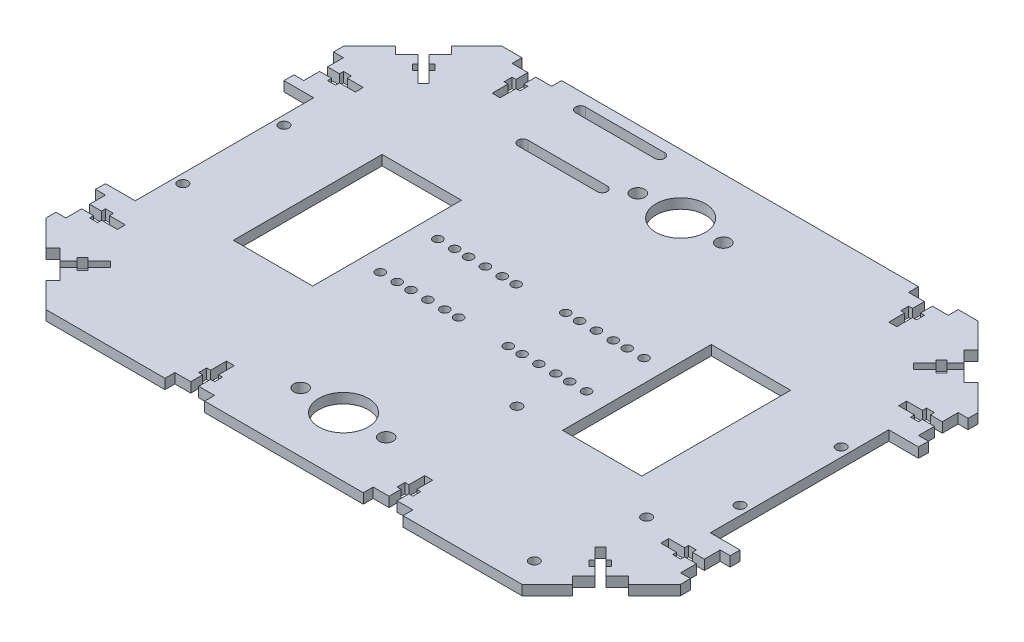
from build123d import *

# Parameters (mm, degrees)
SKETCH2_W                                  = 320
SKETCH2_H                                  = 230
BOSS_EXTRUDE1_DEPTH                        = 5
SKETCH5_W                                  = 15
SKETCH5_H                                  = 90
SKETCH5_W_2                                = 40
SKETCH5_H_2                                = 75
CUT_EXTRUDE1_DEPTH                         = 6
CHAMFER1_SIZE                              = 40
CHAMFER2_SIZE                              = 40
CHAMFER3_SIZE                              = 40
CHAMFER4_SIZE                              = 40
SKETCH22_R                                 = 2.5
CUT_EXTRUDE10_DEPTH                        = 10
SKETCH27_R                                 = 2.25
CUT_EXTRUDE11_DEPTH                        = 10
SKETCH29_R                                 = 3.5
CUT_EXTRUDE12_DEPTH                        = 10
MIRROR7_AT_THE_SECOND_PLANE_COPY_1_SKETC_R = 3.5
MIRROR7_AT_THE_SECOND_PLANE_COPY_1_DEPTH   = 10
CUT_EXTRUDE14_DEPTH                        = 10
SKETCH33_R                                 = 2.5
CUT_EXTRUDE15_DEPTH                        = 10
SKETCH35_W                                 = 20
SKETCH35_H                                 = 5
SKETCH35_W_2                               = 4
SKETCH35_H_2                               = 6
SKETCH35_W_3                               = 2
SKETCH35_H_3                               = 4
SKETCH35_H_4                               = 8
CUT_EXTRUDE16_DEPTH                        = 10
SKETCH36_W                                 = 20
SKETCH36_H                                 = 5
SKETCH36_W_2                               = 4
SKETCH36_H_2                               = 6
SKETCH36_H_3                               = 4
SKETCH36_W_3                               = 2
SKETCH36_H_4                               = 8
CUT_EXTRUDE17_DEPTH                        = 10
CUT_EXTRUDE18_DEPTH                        = 10
MIRROR10_AT_THE_SECOND_PLANE_COPY_1_DEPTH  = 10
CUT_EXTRUDE19_DEPTH                        = 10
MIRROR11_AT_THE_SECOND_PLANE_COPY_1_DEPTH  = 10
SKETCH40_R                                 = 12.5
CUT_EXTRUDE20_DEPTH                        = 10


with BuildPart() as part:
    # Sketch2 → Boss-Extrude1 (new body)
    with BuildSketch(Plane(origin=(0, 0, 0), x_dir=(1, 0, 0), z_dir=(0, 1, 0))):
        Rectangle(SKETCH2_W, SKETCH2_H)
    extrude(amount=BOSS_EXTRUDE1_DEPTH)

    # Sketch5 → Cut-Extrude1 (cut, through all)
    with BuildSketch(Plane(origin=(0, 5, 0), x_dir=(1, 0, 0), z_dir=(0, 1, 0))):
        with Locations((-152.5, 0)):
            Rectangle(SKETCH5_W, SKETCH5_H)
        with Locations((-83, 0)):
            Rectangle(SKETCH5_W_2, SKETCH5_H_2)
        with Locations((83, 0)):
            Rectangle(SKETCH5_W_2, SKETCH5_H_2)
        with Locations((152.5, 0)):
            Rectangle(SKETCH5_W, SKETCH5_H)
    extrude(amount=-CUT_EXTRUDE1_DEPTH, mode=Mode.SUBTRACT)

    # Chamfer1
    chamfer1_edges = [part.edges().sort_by_distance(p)[0] for p in [
        (-160, 2.5, -115),
    ]]
    chamfer(chamfer1_edges, length=CHAMFER1_SIZE)

    # Chamfer2
    chamfer2_edges = [part.edges().sort_by_distance(p)[0] for p in [
        (160, 2.5, -115),
    ]]
    chamfer(chamfer2_edges, length=CHAMFER2_SIZE)

    # Chamfer3
    chamfer3_edges = [part.edges().sort_by_distance(p)[0] for p in [
        (-160, 2.5, 115),
    ]]
    chamfer(chamfer3_edges, length=CHAMFER3_SIZE)

    # Chamfer4
    chamfer4_edges = [part.edges().sort_by_distance(p)[0] for p in [
        (160, 2.5, 115),
    ]]
    chamfer(chamfer4_edges, length=CHAMFER4_SIZE)

    # Sketch22 → Cut-Extrude10 (cut)
    with BuildSketch(Plane(origin=(0, 5, 0), x_dir=(1, 0, 0), z_dir=(0, 1, 0))):
        with Locations((-140.5, 25.5)):
            Circle(SKETCH22_R)
        with Locations((-140.5, -25.5)):
            Circle(SKETCH22_R)
    cut_extrude10 = extrude(amount=-CUT_EXTRUDE10_DEPTH, mode=Mode.SUBTRACT)

    # Mirror5: Cut-Extrude10 across plane
    add(cut_extrude10.mirror(Plane(origin=(0, 0, 0), x_dir=(0, 0, 1), z_dir=(1, 0, 0))), mode=Mode.SUBTRACT)

    # Sketch27 → Cut-Extrude11 (cut)
    with BuildSketch(Plane(origin=(0, 5, 0), x_dir=(1, 0, 0), z_dir=(0, 1, 0))):
        with Locations((-52, 14.579978174)):
            Circle(SKETCH27_R)
        with Locations((-52, -14.413291308)):
            Circle(SKETCH27_R)
        with Locations((-28, 14.579978174)):
            Circle(SKETCH27_R)
        with Locations((-28, -14.419821983)):
            Circle(SKETCH27_R)
        with Locations((-43.5, 14.579978174)):
            Circle(SKETCH27_R)
        with Locations((-36.5, 14.579978174)):
            Circle(SKETCH27_R)
        with Locations((-43.5, -14.413291308)):
            Circle(SKETCH27_R)
        with Locations((-36.5, -14.419821983)):
            Circle(SKETCH27_R)
        with Locations((-19.5, 14.579978174)):
            Circle(SKETCH27_R)
        with Locations((-12.5, 14.579978174)):
            Circle(SKETCH27_R)
        with Locations((-19.5, -14.419821983)):
            Circle(SKETCH27_R)
        with Locations((-12.5, -14.419821983)):
            Circle(SKETCH27_R)
    cut_extrude11 = extrude(amount=-CUT_EXTRUDE11_DEPTH, mode=Mode.SUBTRACT)

    # Mirror6: Cut-Extrude11 across plane
    add(cut_extrude11.mirror(Plane(origin=(0, 0, 0), x_dir=(0, 0, 1), z_dir=(1, 0, 0))), mode=Mode.SUBTRACT)

    # Sketch29 → Cut-Extrude12 (cut)
    with BuildSketch(Plane(origin=(0, 5, 0), x_dir=(1, 0, 0), z_dir=(0, 1, 0))):
        with Locations((-21.551374428, -85)):
            Circle(SKETCH29_R)
    cut_extrude12 = extrude(amount=-CUT_EXTRUDE12_DEPTH, mode=Mode.SUBTRACT)

    # Mirror7: Cut-Extrude12 across plane
    add(cut_extrude12.mirror(Plane.XY), mode=Mode.SUBTRACT)

    # Mirror7 at the second plane: Cut-Extrude12 across plane
    add(cut_extrude12.mirror(Plane(origin=(0, 0, 0), x_dir=(0, 0, 1), z_dir=(1, 0, 0))), mode=Mode.SUBTRACT)

    # Mirror7 at the second plane copy 1 sketc → Mirror7 at the second plane copy 1 (cut)
    with BuildSketch(Plane(origin=(0, 5, 0), x_dir=(-1, 0, 0), z_dir=(0, 1, 0))):
        with Locations((-21.551374428, -85)):
            Circle(MIRROR7_AT_THE_SECOND_PLANE_COPY_1_SKETC_R)
    extrude(amount=-MIRROR7_AT_THE_SECOND_PLANE_COPY_1_DEPTH, mode=Mode.SUBTRACT)

    # Sketch31 → Cut-Extrude14 (cut)
    with BuildSketch(Plane(origin=(0, 5, 0), x_dir=(1, 0, 0), z_dir=(0, 1, 0))):
        with BuildLine():
            Line((-32.499105057, 104.5), (-72.499105057, 104.5))
            ThreePointArc((-72.499105057, 104.5), (-74.999105057, 107), (-72.499105057, 109.5))
            Line((-72.499105057, 109.5), (-32.499105057, 109.5))
            ThreePointArc((-32.499105057, 109.5), (-29.999105057, 107), (-32.499105057, 104.5))
        make_face()
        with BuildLine():
            Line((-32.499105057, 75.5), (-72.499105057, 75.5))
            ThreePointArc((-72.499105057, 75.5), (-74.999105057, 78), (-72.499105057, 80.5))
            Line((-72.499105057, 80.5), (-32.499105057, 80.5))
            ThreePointArc((-32.499105057, 80.5), (-29.999105057, 78), (-32.499105057, 75.5))
        make_face()
    extrude(amount=-CUT_EXTRUDE14_DEPTH, mode=Mode.SUBTRACT)

    # Sketch33 → Cut-Extrude15 (cut)
    with BuildSketch(Plane(origin=(0, 5, 0), x_dir=(1, 0, 0), z_dir=(0, 1, 0))):
        with Locations((40.96, -38.5)):
            Circle(SKETCH33_R)
        with Locations((122.08, -54.2)):
            Circle(SKETCH33_R)
        with Locations((112.9, -101.65)):
            Circle(SKETCH33_R)
    extrude(amount=-CUT_EXTRUDE15_DEPTH, mode=Mode.SUBTRACT)

    # Sketch35 → Cut-Extrude16 (cut)
    with BuildSketch(Plane(origin=(0, 5, 0), x_dir=(1, 0, 0), z_dir=(0, 1, 0))):
        with Locations((50, -112.5)):
            Rectangle(SKETCH35_W, SKETCH35_H)
        with Locations((50, -107)):
            Rectangle(SKETCH35_W_2, SKETCH35_H_2)
        with Locations((53, -102)):
            Rectangle(SKETCH35_W_3, SKETCH35_H_3)
        with Locations((50, -102)):
            Rectangle(SKETCH35_W_2, SKETCH35_H_3)
        with Locations((47, -102)):
            Rectangle(SKETCH35_W_3, SKETCH35_H_3)
        with Locations((50, -96)):
            Rectangle(SKETCH35_W_2, SKETCH35_H_4)
    cut_extrude16 = extrude(amount=-CUT_EXTRUDE16_DEPTH, mode=Mode.SUBTRACT)

    # Mirror8: Cut-Extrude16 across plane
    add(cut_extrude16.mirror(Plane(origin=(0, 0, 0), x_dir=(0, 0, 1), z_dir=(1, 0, 0))), mode=Mode.SUBTRACT)

    # Sketch36 → Cut-Extrude17 (cut)
    with BuildSketch(Plane(origin=(0, 5, 0), x_dir=(1, 0, 0), z_dir=(0, 1, 0))):
        with Locations((-100, 112.5)):
            Rectangle(SKETCH36_W, SKETCH36_H)
        with Locations((-100, 107)):
            Rectangle(SKETCH36_W_2, SKETCH36_H_2)
        with Locations((-100, 102)):
            Rectangle(SKETCH36_W_2, SKETCH36_H_3)
        with Locations((-103, 102)):
            Rectangle(SKETCH36_W_3, SKETCH36_H_3)
        with Locations((-97, 102)):
            Rectangle(SKETCH36_W_3, SKETCH36_H_3)
        with Locations((-100, 96)):
            Rectangle(SKETCH36_W_2, SKETCH36_H_4)
    cut_extrude17 = extrude(amount=-CUT_EXTRUDE17_DEPTH, mode=Mode.SUBTRACT)

    # Mirror9: Cut-Extrude17 across plane
    add(cut_extrude17.mirror(Plane(origin=(0, 0, 0), x_dir=(0, 0, 1), z_dir=(1, 0, 0))), mode=Mode.SUBTRACT)

    # Sketch37 → Cut-Extrude18 (cut)
    with BuildSketch(Plane(origin=(0, 5, 0), x_dir=(1, 0, 0), z_dir=(0, 1, 0))):
        Polygon((-155, -50), (-160, -50), (-160, -70), (-155, -70), (-155, -62), (-149, -62), (-149, -64), (-145, -64), (-145, -62), (-137, -62), (-137, -58), (-145, -58), (-145, -56), (-149, -56), (-149, -58), (-155, -58), align=None)
    cut_extrude18 = extrude(amount=-CUT_EXTRUDE18_DEPTH, mode=Mode.SUBTRACT)

    # Mirror10: Cut-Extrude18 across plane
    add(cut_extrude18.mirror(Plane.XY), mode=Mode.SUBTRACT)

    # Mirror10 at the second plane: Cut-Extrude18 across plane
    add(cut_extrude18.mirror(Plane(origin=(0, 0, 0), x_dir=(0, 0, 1), z_dir=(1, 0, 0))), mode=Mode.SUBTRACT)

    # Mirror10 at the second plane copy 1 sket → Mirror10 at the second plane copy 1 (cut)
    with BuildSketch(Plane(origin=(0, 5, 0), x_dir=(-1, 0, 0), z_dir=(0, 1, 0))):
        Polygon((-155, -50), (-160, -50), (-160, -70), (-155, -70), (-155, -62), (-149, -62), (-149, -64), (-145, -64), (-145, -62), (-137, -62), (-137, -58), (-145, -58), (-145, -56), (-149, -56), (-149, -58), (-155, -58), align=None)
    extrude(amount=-MIRROR10_AT_THE_SECOND_PLANE_COPY_1_DEPTH, mode=Mode.SUBTRACT)

    # Sketch39 → Cut-Extrude19 (cut)
    with BuildSketch(Plane(origin=(0, 5, 0), x_dir=(1, 0, 0), z_dir=(0, 1, 0))):
        Polygon((-129.192388155, -98.736544033), (-143.334523779, -84.594408409), (-146.870057685, -88.129942315), (-132.727922061, -102.272077939), align=None)
        Polygon((-133.435028843, -86.008621971), (-137.67766953, -90.251262658), (-134.849242405, -93.079689783), (-130.606601718, -88.837049096), align=None)
        Polygon((-130.606601718, -83.180194847), (-133.435028843, -86.008621971), (-130.606601718, -88.837049096), (-127.778174593, -86.008621971), align=None)
        Polygon((-134.849242405, -84.594408409), (-133.435028843, -86.008621971), (-130.606601718, -83.180194847), (-132.02081528, -81.765981284), align=None)
        Polygon((-127.778174593, -86.008621971), (-130.606601718, -88.837049096), (-129.192388155, -90.251262658), (-126.363961031, -87.422835534), align=None)
        Polygon((-124.949747468, -77.523340597), (-130.606601718, -83.180194847), (-127.778174593, -86.008621971), (-122.121320344, -80.351767722), align=None)
    cut_extrude19 = extrude(amount=-CUT_EXTRUDE19_DEPTH, mode=Mode.SUBTRACT)

    # Mirror11: Cut-Extrude19 across plane
    add(cut_extrude19.mirror(Plane(origin=(0, 0, 0), x_dir=(0, 0, 1), z_dir=(1, 0, 0))), mode=Mode.SUBTRACT)

    # Mirror11 at the second plane: Cut-Extrude19 across plane
    add(cut_extrude19.mirror(Plane.XY), mode=Mode.SUBTRACT)

    # Mirror11 at the second plane copy 1 sket → Mirror11 at the second plane copy 1 (cut)
    with BuildSketch(Plane(origin=(0, 5, 0), x_dir=(-1, 0, 0), z_dir=(0, 1, 0))):
        Polygon((-129.192388155, -98.736544033), (-143.334523779, -84.594408409), (-146.870057685, -88.129942315), (-132.727922061, -102.272077939), align=None)
        Polygon((-133.435028843, -86.008621971), (-137.67766953, -90.251262658), (-134.849242405, -93.079689783), (-130.606601718, -88.837049096), align=None)
        Polygon((-130.606601718, -83.180194847), (-133.435028843, -86.008621971), (-130.606601718, -88.837049096), (-127.778174593, -86.008621971), align=None)
        Polygon((-134.849242405, -84.594408409), (-133.435028843, -86.008621971), (-130.606601718, -83.180194847), (-132.02081528, -81.765981284), align=None)
        Polygon((-127.778174593, -86.008621971), (-130.606601718, -88.837049096), (-129.192388155, -90.251262658), (-126.363961031, -87.422835534), align=None)
        Polygon((-124.949747468, -77.523340597), (-130.606601718, -83.180194847), (-127.778174593, -86.008621971), (-122.121320344, -80.351767722), align=None)
    extrude(amount=-MIRROR11_AT_THE_SECOND_PLANE_COPY_1_DEPTH, mode=Mode.SUBTRACT)

    # Sketch40 → Cut-Extrude20 (cut)
    with BuildSketch(Plane(origin=(0, 5, 0), x_dir=(1, 0, 0), z_dir=(0, 1, 0))):
        with Locations((0.051374428, -85)):
            Circle(SKETCH40_R)
    cut_extrude20 = extrude(amount=-CUT_EXTRUDE20_DEPTH, mode=Mode.SUBTRACT)

    # Mirror12: Cut-Extrude20 across plane
    add(cut_extrude20.mirror(Plane.XY), mode=Mode.SUBTRACT)


solid = part.part
